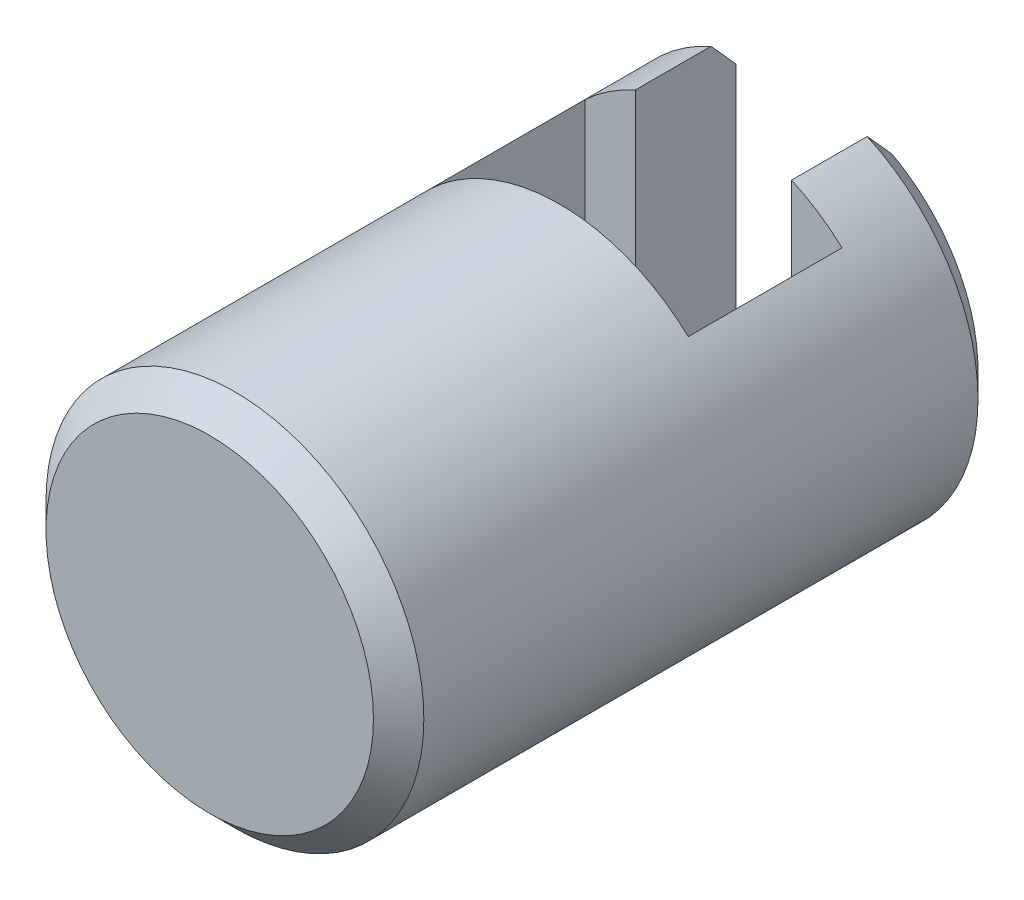
from build123d import *

# Parameters (mm, degrees)
SKETCH_1_R          = 7.5
EXTRUDE_1_DEPTH     = 24
CUT_EXTRUDE_1_DEPTH = 10
CHAMFER_1_SIZE      = 1
CHAMFER_2_SIZE      = 1


with BuildPart() as part:
    # 草图1 → 凸台-拉伸1 (new body)
    with BuildSketch(Plane.XY):
        Circle(SKETCH_1_R)
    extrude(amount=EXTRUDE_1_DEPTH)

    # 草图2 → 切除-拉伸1 (cut, symmetric)
    with BuildSketch(Plane(origin=(0, 0, 0), x_dir=(1, 0, 0), z_dir=(0, 1, 0))):
        Polygon((3.1, 0), (-3.1, 0), (-3.1, -4), (-5.1, -4), (-5.1, -10.1), (5.1, -10.1), (5.1, -4), (3.1, -4), align=None)
    extrude(amount=CUT_EXTRUDE_1_DEPTH, both=True, mode=Mode.SUBTRACT)

    # 倒角1
    chamfer_1_edges = [part.edges().sort_by_distance(p)[0] for p in [
        (-7.5, 0, 24),
    ]]
    chamfer(chamfer_1_edges, length=CHAMFER_1_SIZE)

    # 倒角2
    chamfer_2_edges = [part.edges().sort_by_distance(p)[0] for p in [
        (-7.5, 0, 0),
        (6.304760106, -4.062019202, 0),
    ]]
    chamfer(chamfer_2_edges, length=CHAMFER_2_SIZE)


solid = part.part
